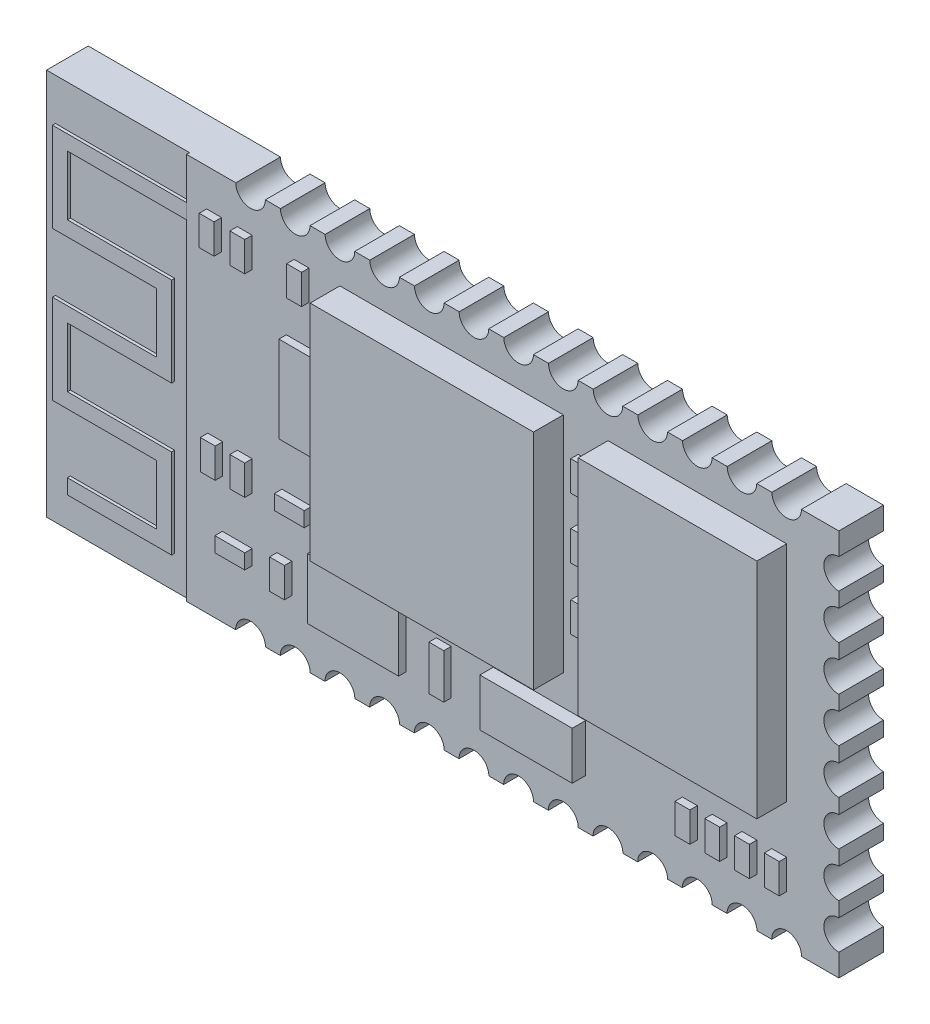
from build123d import *

# Parameters (mm, degrees)
SKETCH1_W            = 26.7
SKETCH1_H            = 13
BOSS_EXTRUDE1_DEPTH  = 1.5
SKETCH2_W            = 6
SKETCH2_H            = 7.5
BOSS_EXTRUDE2_DEPTH  = 1
SKETCH3_W            = 7.5
SKETCH3_H            = 7.5
BOSS_EXTRUDE3_DEPTH  = 1
SKETCH4_W            = 4.8
SKETCH4_H            = 13
CUT_EXTRUDE1_DEPTH   = 0.1
SKETCH5_W            = 0.5
SKETCH5_H            = 1
BOSS_EXTRUDE4_DEPTH  = 0.25
SKETCH6_W            = 3.1
SKETCH6_H            = 1.6
BOSS_EXTRUDE5_DEPTH  = 0.45
SKETCH7_W            = 3.05896952
SKETCH7_H            = 2.035652533
BOSS_EXTRUDE6_DEPTH  = 0.25
SKETCH8_W            = 0.5
SKETCH8_H            = 1.5
BOSS_EXTRUDE7_DEPTH  = 0.25
SKETCH9_W            = 0.5
SKETCH9_H            = 1
BOSS_EXTRUDE8_DEPTH  = 0.25
SKETCH10_W           = 1.306192625
SKETCH10_H           = 2.902650279
BOSS_EXTRUDE9_DEPTH  = 0.25
SKETCH11_W           = 0.5
SKETCH11_H           = 1
SKETCH11_W_2         = 1
SKETCH11_H_2         = 0.5
BOSS_EXTRUDE10_DEPTH = 0.25
CUT_EXTRUDE2_DEPTH   = 2.5
CUT_EXTRUDE3_DEPTH   = 2.5
CUT_EXTRUDE4_DEPTH   = 2.5
BOSS_EXTRUDE11_DEPTH = 0.1


with BuildPart() as part:
    # Sketch1 → Boss-Extrude1 (new body)
    with BuildSketch(Plane.XY):
        with Locations((13.35, 6.5)):
            Rectangle(SKETCH1_W, SKETCH1_H)
    extrude(amount=BOSS_EXTRUDE1_DEPTH)

    # Sketch2 → Boss-Extrude2 (add)
    with BuildSketch(Plane.XY.offset(1.5)):
        with Locations((21.95, 8)):
            Rectangle(SKETCH2_W, SKETCH2_H)
    extrude(amount=BOSS_EXTRUDE2_DEPTH)

    # Sketch3 → Boss-Extrude3 (add)
    with BuildSketch(Plane.XY.offset(1.5)):
        with Locations((13.7, 8)):
            Rectangle(SKETCH3_W, SKETCH3_H)
    extrude(amount=BOSS_EXTRUDE3_DEPTH)

    # Sketch4 → Cut-Extrude1 (cut)
    with BuildSketch(Plane.XY.offset(1.5)):
        with Locations((2.4, 6.5)):
            Rectangle(SKETCH4_W, SKETCH4_H)
    extrude(amount=-CUT_EXTRUDE1_DEPTH, mode=Mode.SUBTRACT)

    # Sketch5 → Boss-Extrude4 (add)
    with BuildSketch(Plane.XY.offset(1.5)):
        with Locations((24.7, 2.136917197)):
            Rectangle(SKETCH5_W, SKETCH5_H)
        with Locations((23.7, 2.136917197)):
            Rectangle(SKETCH5_W, SKETCH5_H)
        with Locations((22.7, 2.136917197)):
            Rectangle(SKETCH5_W, SKETCH5_H)
        with Locations((21.7, 2.136917197)):
            Rectangle(SKETCH5_W, SKETCH5_H)
        with Locations((18.2, 10.349961641)):
            Rectangle(SKETCH5_W, SKETCH5_H)
        with Locations((18.2, 8.31847615)):
            Rectangle(SKETCH5_W, SKETCH5_H)
        with Locations((18.2, 6.247416267)):
            Rectangle(SKETCH5_W, SKETCH5_H)
    extrude(amount=BOSS_EXTRUDE4_DEPTH)

    # Sketch6 → Boss-Extrude5 (add)
    with BuildSketch(Plane.XY.offset(1.5)):
        with Locations((16.65, 2.436917197)):
            Rectangle(SKETCH6_W, SKETCH6_H)
    extrude(amount=BOSS_EXTRUDE5_DEPTH)

    # Sketch7 → Boss-Extrude6 (add)
    with BuildSketch(Plane.XY.offset(1.5)):
        with Locations((10.641813919, 2.654743464)):
            Rectangle(SKETCH7_W, SKETCH7_H)
    extrude(amount=BOSS_EXTRUDE6_DEPTH)

    # Sketch8 → Boss-Extrude7 (add)
    with BuildSketch(Plane.XY.offset(1.5)):
        with Locations((13.437713925, 2.386917197)):
            Rectangle(SKETCH8_W, SKETCH8_H)
    extrude(amount=BOSS_EXTRUDE7_DEPTH)

    # Sketch9 → Boss-Extrude8 (add)
    with BuildSketch(Plane.XY.offset(1.5)):
        with Locations((8.661664243, 11.25)):
            Rectangle(SKETCH9_W, SKETCH9_H)
        with Locations((5.725465525, 11.25)):
            Rectangle(SKETCH9_W, SKETCH9_H)
        with Locations((6.754336121, 11.25)):
            Rectangle(SKETCH9_W, SKETCH9_H)
    extrude(amount=BOSS_EXTRUDE8_DEPTH)

    # Sketch10 → Boss-Extrude9 (add)
    with BuildSketch(Plane.XY.offset(1.5)):
        with Locations((8.805654417, 7.977876916)):
            Rectangle(SKETCH10_W, SKETCH10_H)
    extrude(amount=BOSS_EXTRUDE9_DEPTH)

    # Sketch11 → Boss-Extrude10 (add)
    with BuildSketch(Plane.XY.offset(1.5)):
        with Locations((6.754336121, 4.75)):
            Rectangle(SKETCH11_W, SKETCH11_H)
        with Locations((5.763111384, 4.75)):
            Rectangle(SKETCH11_W, SKETCH11_H)
        with Locations((8.502538747, 4.616002574)):
            Rectangle(SKETCH11_W_2, SKETCH11_H_2)
        with Locations((8.086576923, 2.437961819)):
            Rectangle(SKETCH11_W, SKETCH11_H)
        with Locations((6.504336121, 2.389486891)):
            Rectangle(SKETCH11_W_2, SKETCH11_H_2)
    extrude(amount=BOSS_EXTRUDE10_DEPTH)

    # Sketch12 → Cut-Extrude2 (cut, through all)
    with BuildSketch(Plane.XY.offset(1.5)):
        with BuildLine():
            Line((26.7, 0.749290759), (26.7, 1.750709241))
            ThreePointArc((26.7, 1.750709241), (26.199290759, 1.25), (26.7, 0.749290759))
        make_face()
        with BuildLine():
            Line((26.7, 2.249290759), (26.7, 3.250709241))
            ThreePointArc((26.7, 3.250709241), (26.199290759, 2.75), (26.7, 2.249290759))
        make_face()
        with BuildLine():
            Line((26.7, 3.749290759), (26.7, 4.750709241))
            ThreePointArc((26.7, 4.750709241), (26.199290759, 4.25), (26.7, 3.749290759))
        make_face()
        with BuildLine():
            Line((26.7, 5.249290759), (26.7, 6.250709241))
            ThreePointArc((26.7, 6.250709241), (26.199290759, 5.75), (26.7, 5.249290759))
        make_face()
        with BuildLine():
            Line((26.7, 6.749290759), (26.7, 7.750709241))
            ThreePointArc((26.7, 7.750709241), (26.199290759, 7.25), (26.7, 6.749290759))
        make_face()
        with BuildLine():
            Line((26.7, 8.249290759), (26.7, 9.250709241))
            ThreePointArc((26.7, 9.250709241), (26.199290759, 8.75), (26.7, 8.249290759))
        make_face()
        with BuildLine():
            Line((26.7, 9.749290759), (26.7, 10.750709241))
            ThreePointArc((26.7, 10.750709241), (26.199290759, 10.25), (26.7, 9.749290759))
        make_face()
        with BuildLine():
            Line((26.7, 11.249290759), (26.7, 12.250709241))
            ThreePointArc((26.7, 12.250709241), (26.199290759, 11.75), (26.7, 11.249290759))
        make_face()
    extrude(amount=-CUT_EXTRUDE2_DEPTH, mode=Mode.SUBTRACT)

    # Sketch13 → Cut-Extrude3 (cut, through all)
    with BuildSketch(Plane.XY.offset(1.5)):
        with BuildLine():
            Line((25.446320949, 13), (24.453679051, 13))
            ThreePointArc((24.453679051, 13), (24.95, 12.503679051), (25.446320949, 13))
        make_face()
        with BuildLine():
            Line((23.946320949, 13), (22.953679051, 13))
            ThreePointArc((22.953679051, 13), (23.45, 12.503679051), (23.946320949, 13))
        make_face()
        with BuildLine():
            Line((22.446320949, 13), (21.453679051, 13))
            ThreePointArc((21.453679051, 13), (21.95, 12.503679051), (22.446320949, 13))
        make_face()
        with BuildLine():
            Line((20.946320949, 13), (19.953679051, 13))
            ThreePointArc((19.953679051, 13), (20.45, 12.503679051), (20.946320949, 13))
        make_face()
        with BuildLine():
            Line((19.446320949, 13), (18.453679051, 13))
            ThreePointArc((18.453679051, 13), (18.95, 12.503679051), (19.446320949, 13))
        make_face()
        with BuildLine():
            Line((17.946320949, 13), (16.953679051, 13))
            ThreePointArc((16.953679051, 13), (17.45, 12.503679051), (17.946320949, 13))
        make_face()
        with BuildLine():
            Line((16.446320949, 13), (15.453679051, 13))
            ThreePointArc((15.453679051, 13), (15.95, 12.503679051), (16.446320949, 13))
        make_face()
        with BuildLine():
            Line((14.946320949, 13), (13.953679051, 13))
            ThreePointArc((13.953679051, 13), (14.45, 12.503679051), (14.946320949, 13))
        make_face()
        with BuildLine():
            Line((13.446320949, 13), (12.453679051, 13))
            ThreePointArc((12.453679051, 13), (12.95, 12.503679051), (13.446320949, 13))
        make_face()
        with BuildLine():
            Line((11.946320949, 13), (10.953679051, 13))
            ThreePointArc((10.953679051, 13), (11.45, 12.503679051), (11.946320949, 13))
        make_face()
        with BuildLine():
            Line((10.446320949, 13), (9.453679051, 13))
            ThreePointArc((9.453679051, 13), (9.95, 12.503679051), (10.446320949, 13))
        make_face()
        with BuildLine():
            Line((8.946320949, 13), (7.953679051, 13))
            ThreePointArc((7.953679051, 13), (8.45, 12.503679051), (8.946320949, 13))
        make_face()
        with BuildLine():
            Line((7.446320949, 13), (6.453679051, 13))
            ThreePointArc((6.453679051, 13), (6.95, 12.503679051), (7.446320949, 13))
        make_face()
    extrude(amount=-CUT_EXTRUDE3_DEPTH, mode=Mode.SUBTRACT)

    # Sketch15 → Cut-Extrude4 (cut, through all)
    with BuildSketch(Plane.XY.offset(1.5)):
        with BuildLine():
            Line((24.448599989, 0), (25.451400011, 0))
            ThreePointArc((25.451400011, 0), (24.95, 0.501400011), (24.448599989, 0))
        make_face()
        with BuildLine():
            Line((22.948599989, 0), (23.951400011, 0))
            ThreePointArc((23.951400011, 0), (23.45, 0.501400011), (22.948599989, 0))
        make_face()
        with BuildLine():
            Line((21.448599989, 0), (22.451400011, 0))
            ThreePointArc((22.451400011, 0), (21.95, 0.501400011), (21.448599989, 0))
        make_face()
        with BuildLine():
            Line((19.948599989, 0), (20.951400011, 0))
            ThreePointArc((20.951400011, 0), (20.45, 0.501400011), (19.948599989, 0))
        make_face()
        with BuildLine():
            Line((18.448599989, 0), (19.451400011, 0))
            ThreePointArc((19.451400011, 0), (18.95, 0.501400011), (18.448599989, 0))
        make_face()
        with BuildLine():
            Line((16.948599989, 0), (17.951400011, 0))
            ThreePointArc((17.951400011, 0), (17.45, 0.501400011), (16.948599989, 0))
        make_face()
        with BuildLine():
            Line((15.448599989, 0), (16.451400011, 0))
            ThreePointArc((16.451400011, 0), (15.95, 0.501400011), (15.448599989, 0))
        make_face()
        with BuildLine():
            Line((13.948599989, 0), (14.951400011, 0))
            ThreePointArc((14.951400011, 0), (14.45, 0.501400011), (13.948599989, 0))
        make_face()
        with BuildLine():
            Line((12.448599989, 0), (13.451400011, 0))
            ThreePointArc((13.451400011, 0), (12.95, 0.501400011), (12.448599989, 0))
        make_face()
        with BuildLine():
            Line((10.948599989, 0), (11.951400011, 0))
            ThreePointArc((11.951400011, 0), (11.45, 0.501400011), (10.948599989, 0))
        make_face()
        with BuildLine():
            Line((9.448599989, 0), (10.451400011, 0))
            ThreePointArc((10.451400011, 0), (9.95, 0.501400011), (9.448599989, 0))
        make_face()
        with BuildLine():
            Line((7.948599989, 0), (8.951400011, 0))
            ThreePointArc((8.951400011, 0), (8.45, 0.501400011), (7.948599989, 0))
        make_face()
        with BuildLine():
            Line((6.448599989, 0), (7.451400011, 0))
            ThreePointArc((7.451400011, 0), (6.95, 0.501400011), (6.448599989, 0))
        make_face()
    extrude(amount=-CUT_EXTRUDE4_DEPTH, mode=Mode.SUBTRACT)


with BuildPart() as body_2:
    # Sketch17 → Boss-Extrude11 (new body)
    with BuildSketch(Plane.XY.offset(1.4)):
        Polygon((4.8, 11.596861707), (0.3, 11.596861707), (0.3, 8.596861707), (3.8, 8.596861707), (3.8, 6.596526092), (0.3, 6.596526092), (0.3, 3.596526092), (3.8, 3.596526092), (3.8, 1.596526092), (0.8, 1.596526092), (0.8, 1.096526092), (4.3, 1.096526092), (4.3, 4.096526092), (0.8, 4.096526092), (0.8, 6.096526092), (4.3, 6.096526092), (4.3, 9.096526092), (0.8, 9.096526092), (0.8, 11.096526092), (4.8, 11.096526092), align=None)
    extrude(amount=BOSS_EXTRUDE11_DEPTH)


solid = Compound([part.part, body_2.part])
